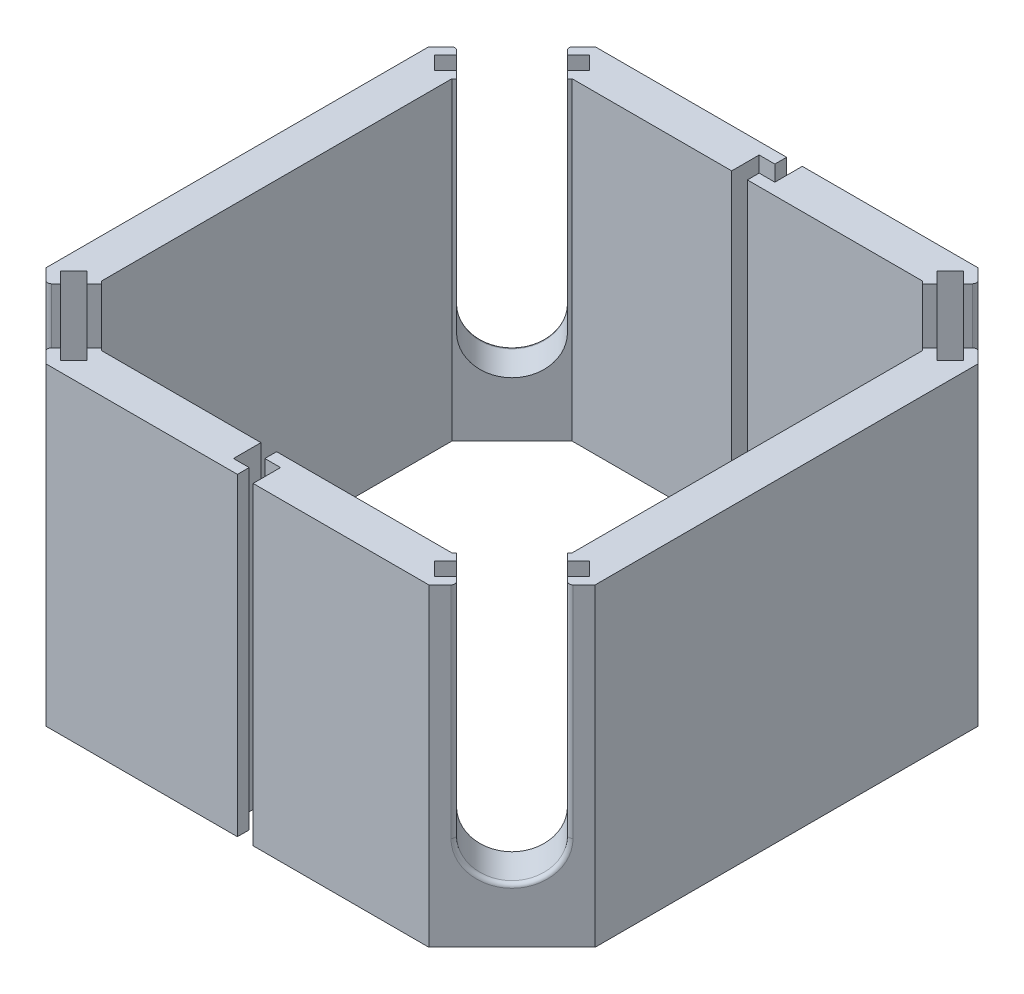
from build123d import *

# Parameters (mm, degrees)
BOSS_EXTRUDE1_DEPTH      = 20
CUT_EXTRUDE1_REACH       = 33.82
CUT_EXTRUDE2_REACH       = 51.928
CIRPATTERN3_COUNT        = 4
CUT_EXTRUDE3_DEPTH       = 14
CIRPATTERN4_COUNT        = 4
CIRPATTERN4_COPY_1_DEPTH = 14
CIRPATTERN4_COPY_2_DEPTH = 14
CIRPATTERN4_COPY_3_DEPTH = 14
FILLET1_R                = 0.25
CUT_EXTRUDE4_DEPTH       = 32.819805153


with BuildPart() as part:
    # Sketch1 → Boss-Extrude1 (new body)
    with BuildSketch(Plane(origin=(0, 0, 0), x_dir=(1, 0, 0), z_dir=(0, 1, 0))):
        Polygon((-12.196699141, 17.5), (-17.5, 12.196699141), (-17.5, -12.196699141), (-12.196699141, -17.5), (12.196699141, -17.5), (17.5, -12.196699141), (17.5, 12.196699141), (12.196699141, 17.5), align=None)
    extrude(amount=BOSS_EXTRUDE1_DEPTH)

    # Sketch2 → Cut-Extrude1 (cut, up to next)
    with BuildSketch(Plane(origin=(0, 20, 0), x_dir=(1, 0, 0), z_dir=(0, 1, 0)), mode=Mode.PRIVATE) as cut_extrude1_sk1:
        Polygon((-11.161165235, 15), (-15, 11.161165235), (-15, -11.161165235), (-11.161165235, -15), (11.161165235, -15), (15, -11.161165235), (15, 11.161165235), (11.161165235, 15), align=None)
    cut_extrude1_tool1 = extrude(cut_extrude1_sk1.sketch, amount=-CUT_EXTRUDE1_REACH, mode=Mode.PRIVATE) & part.part
    add(cut_extrude1_tool1.solids().sort_by_distance((0, 20, 0))[0], mode=Mode.SUBTRACT)

    # Sketch4 → Cut-Extrude2 (cut, up to next)
    with BuildSketch(Plane(origin=(14.848349571, 0, 14.848349571), x_dir=(0.7071067811865472, 0, -0.7071067811865478), z_dir=(0.7071067811865478, 0, 0.7071067811865472)), mode=Mode.PRIVATE) as cut_extrude2_sk1:
        with BuildLine():
            Line((-2.5, 20), (2.5, 20))
            Line((2.5, 20), (2.5, 6))
            ThreePointArc((2.5, 6), (0, 3.5), (-2.5, 6))
            Line((-2.5, 6), (-2.5, 20))
        make_face()
    cut_extrude2_tool1 = extrude(cut_extrude2_sk1.sketch, amount=-CUT_EXTRUDE2_REACH, mode=Mode.PRIVATE) & part.part
    cut_extrude2 = cut_extrude2_tool1.solids().sort_by_distance((14.84835, 12.0085, 14.84835))[0]
    add(cut_extrude2, mode=Mode.SUBTRACT)

    # CirPattern3: Cut-Extrude2 ×4 about axis
    cirpattern3_axis = Axis((0, 0, 0), (0, -1, 0))
    for i in range(1, CIRPATTERN3_COUNT):
        add(cut_extrude2.rotate(cirpattern3_axis, i * 360 / CIRPATTERN3_COUNT), mode=Mode.SUBTRACT)

    # Sketch5 → Cut-Extrude3 (cut)
    with BuildSketch(Plane(origin=(0, 20, 0), x_dir=(1, 0, 0), z_dir=(0, 1, 0))):
        Polygon((11.772435072, -15.307968978), (12.62096321, -16.156497116), (11.913856429, -16.863603897), (11.065328291, -16.01507576), align=None)
    cut_extrude3 = extrude(amount=-CUT_EXTRUDE3_DEPTH, mode=Mode.SUBTRACT)

    # Mirror1: Cut-Extrude3 across plane
    add(cut_extrude3.mirror(Plane(origin=(0, 0, 0), x_dir=(0.7071067811865482, 0, 0.7071067811865468), z_dir=(0.7071067811865468, 0, -0.7071067811865482))), mode=Mode.SUBTRACT)

    # CirPattern4: Cut-Extrude3 ×4 about axis
    cirpattern4_axis = Axis((0, 0, 0), (0, -1, 0))
    for i in range(1, CIRPATTERN4_COUNT):
        add(cut_extrude3.rotate(cirpattern4_axis, i * 360 / CIRPATTERN4_COUNT), mode=Mode.SUBTRACT)

    # CirPattern4 copy 1 sketch → CirPattern4 copy 1 (cut)
    with BuildSketch(Plane(origin=(0, 20, 0), x_dir=(-1, 0, 0), z_dir=(0, 1, 0))):
        Polygon((11.772435072, 15.307968978), (12.62096321, 16.156497116), (11.913856429, 16.863603897), (11.065328291, 16.01507576), align=None)
    extrude(amount=-CIRPATTERN4_COPY_1_DEPTH, mode=Mode.SUBTRACT)

    # CirPattern4 copy 2 sketch → CirPattern4 copy 2 (cut)
    with BuildSketch(Plane(origin=(0, 20, 0), x_dir=(0, 0, -1), z_dir=(0, 1, 0))):
        Polygon((11.772435072, 15.307968978), (12.62096321, 16.156497116), (11.913856429, 16.863603897), (11.065328291, 16.01507576), align=None)
    extrude(amount=-CIRPATTERN4_COPY_2_DEPTH, mode=Mode.SUBTRACT)

    # CirPattern4 copy 3 sketch → CirPattern4 copy 3 (cut)
    with BuildSketch(Plane(origin=(0, 20, 0), x_dir=(1, 0, 0), z_dir=(0, 1, 0))):
        Polygon((11.772435072, 15.307968978), (12.62096321, 16.156497116), (11.913856429, 16.863603897), (11.065328291, 16.01507576), align=None)
    extrude(amount=-CIRPATTERN4_COPY_3_DEPTH, mode=Mode.SUBTRACT)

    # Fillet1
    fillet1_edges = [part.edges().sort_by_distance(p)[0] for p in [
        (16.616116524, 13, 13.080582618),
        (14.848349571, 3.5, 14.848349571),
        (13.080582618, 13, 16.616116524),
        (-13.080582618, 13, -16.616116524),
        (-14.848349571, 3.5, -14.848349571),
        (-16.616116524, 13, -13.080582618),
        (16.616116524, 13, -13.080582618),
        (14.848349571, 3.5, -14.848349571),
        (-13.080582618, 13, 16.616116524),
        (-14.848349571, 3.5, 14.848349571),
        (13.080582618, 13, -16.616116524),
        (-16.616116524, 13, 13.080582618),
    ]]
    fillet(fillet1_edges, radius=FILLET1_R)

    # Sketch6 → Cut-Extrude4 (cut, through all)
    with BuildSketch(Plane(origin=(0, 20, 0), x_dir=(1, 0, 0), z_dir=(0, 1, 0))):
        Polygon((0, -15), (-1, -15), (-1, -16.75), (0, -16.75), (0, -17.5), (1, -17.5), (1, -15.75), (0, -15.75), align=None)
    cut_extrude4 = extrude(amount=-CUT_EXTRUDE4_DEPTH, mode=Mode.SUBTRACT)

    # Mirror2: Cut-Extrude4 across plane
    add(cut_extrude4.mirror(Plane.XY), mode=Mode.SUBTRACT)


solid = part.part
